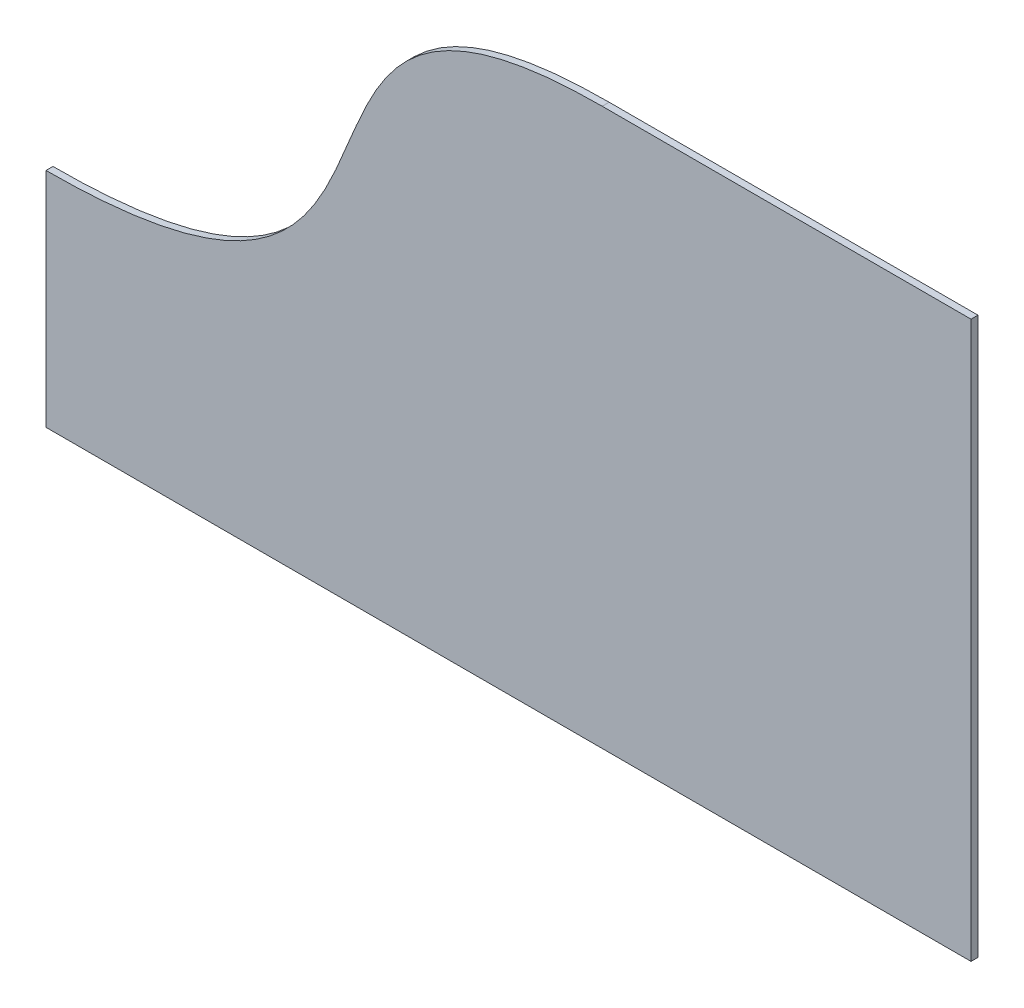
from build123d import *

# Parameters (mm, degrees)
BOSS_EXTRUDE1_DEPTH = 3.175


with BuildPart() as part:
    # Sketch1 → Boss-Extrude1 (new body)
    with BuildSketch(Plane.XY):
        with BuildLine():
            Line((149.647712361, 213.341972064), (-18.782287639, 213.341972064))
            add(Edge.make_bspline(
                [(-18.782287639, 213.341972064), (-196.582287639, 213.341972064), (-69.582287639, 60.941972064), (-272.782287639, 60.941972064)],
                knots=[0, 0, 0, 0, 1, 1, 1, 1], degree=3))
            Line((-272.782287639, 60.941972064), (-272.782287639, -40.658027936))
            Line((-272.782287639, -40.658027936), (149.647712361, -40.658027936))
            Line((149.647712361, -40.658027936), (149.647712361, 213.341972064))
        make_face()
    extrude(amount=BOSS_EXTRUDE1_DEPTH)


solid = part.part
